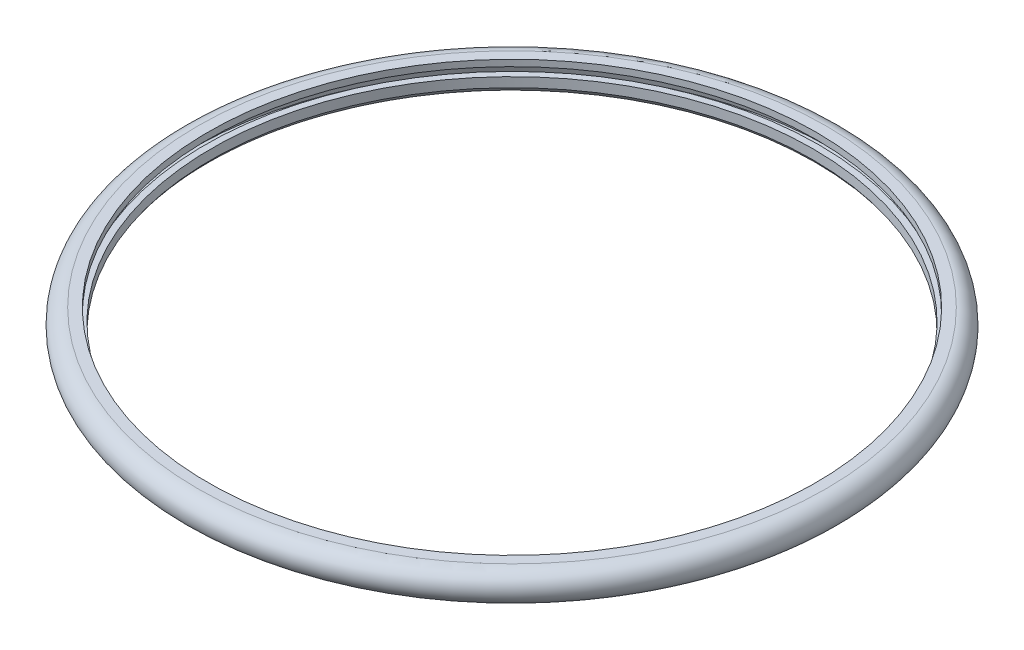
from build123d import *


with BuildPart() as part:
    # Sketch1 → Revolve1 (revolve)
    with BuildSketch(Plane.XY):
        with BuildLine():
            Line((-24.6875, 1.25), (-25, 0))
            Line((-25, 0), (-24, 0))
            Line((-24, 0), (-24, 0.75))
            Line((-24, 0.75), (-23.5, 0.75))
            Line((-23.5, 0.75), (-23.5, 0))
            ThreePointArc((-23.5, 0), (-25.58614621, -0.069044127), (-24.5625, 1.75))
            Line((-24.5625, 1.75), (-23.75, 1.75))
            Line((-23.75, 1.75), (-23.75, 1.25))
            Line((-23.75, 1.25), (-24.6875, 1.25))
        make_face()
    revolve(axis=Axis((0, 0, 0), (0, 1, 0)))


solid = part.part
